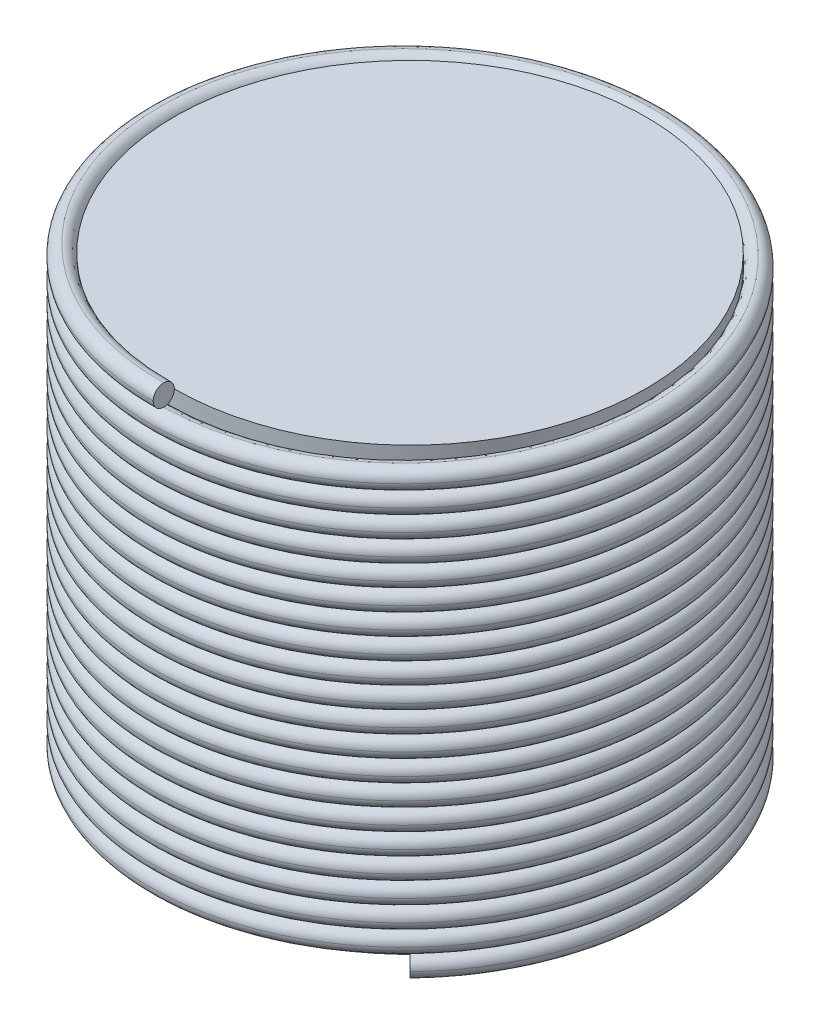
from build123d import *

# Parameters (mm, degrees)
BASE_R              = 8.925
BOSS_EXTRUDE1_DEPTH = 16.7
SWEEP1_PITCH        = 0.8
SWEEP1_HEIGHT       = 16.7
SWEEP1_RADIUS       = 9.325
SWEEP1_START_ANGLE  = 180
WINDING_R           = 0.4


with BuildPart() as part:
    # Base → Boss-Extrude1 (new body)
    with BuildSketch(Plane(origin=(0, 0, 0), x_dir=(1, 0, 0), z_dir=(0, 1, 0))):
        Circle(BASE_R)
    extrude(amount=BOSS_EXTRUDE1_DEPTH)


with BuildPart() as body_2:
    # Sweep1: sweep along a helix
    with BuildLine() as sweep1_path:
        add(Helix(SWEEP1_PITCH, SWEEP1_HEIGHT, SWEEP1_RADIUS, center=(0, 16.7, 0), direction=(0, -1, 0), mode=Mode.PRIVATE).rotate(Axis((0, 16.7, 0), (0, -1, 0)), SWEEP1_START_ANGLE))
    # Winding → Sweep1 (sweep)
    with BuildSketch(Plane(origin=(0, 0, 0), x_dir=(0, 0, -1), z_dir=(1, 0, 0))):
        with Locations((-9.325, 16.7)):
            Circle(WINDING_R)
    sweep(path=sweep1_path.line, is_frenet=True)


solid = Compound([part.part, body_2.part])
